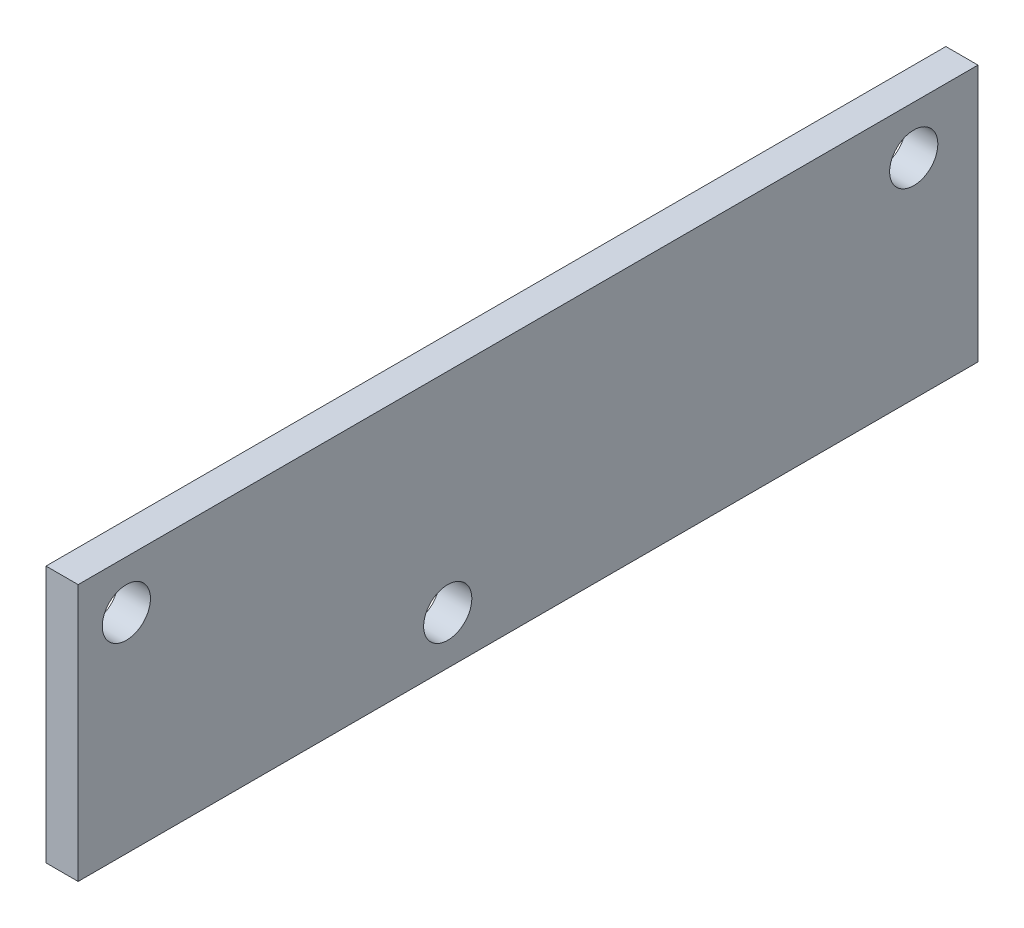
from build123d import *

# Parameters (mm, degrees)
SKETCH1_W           = 355.6
SKETCH1_H           = 101.6
BOSS_EXTRUDE1_DEPTH = 6.35
CUT_EXTRUDE1_REACH  = 14.7
SKETCH2_R           = 9.525


with BuildPart() as part:
    # Sketch1 → Boss-Extrude1 (new body, symmetric)
    with BuildSketch(Plane(origin=(0, 0, 0), x_dir=(0, 0, -1), z_dir=(1, 0, 0))):
        Rectangle(SKETCH1_W, SKETCH1_H)
    extrude(amount=BOSS_EXTRUDE1_DEPTH, both=True)

    # Sketch2 → Cut-Extrude1 (cut, up to next)
    with BuildSketch(Plane(origin=(6.35, 0, 0), x_dir=(0, 0, -1), z_dir=(1, 0, 0)), mode=Mode.PRIVATE) as cut_extrude1_sk1:
        with Locations((-158.75, 31.75)):
            Circle(SKETCH2_R)
    cut_extrude1_tool1 = extrude(cut_extrude1_sk1.sketch, amount=-CUT_EXTRUDE1_REACH, mode=Mode.PRIVATE) & part.part
    add(cut_extrude1_tool1.solids().sort_by_distance((6.35, 31.75, 158.75))[0], mode=Mode.SUBTRACT)
    # Sketch2 → Cut-Extrude1 (cut, up to next)
    with BuildSketch(Plane(origin=(6.35, 0, 0), x_dir=(0, 0, -1), z_dir=(1, 0, 0)), mode=Mode.PRIVATE) as cut_extrude1_sk2:
        with Locations((-31.75, -31.75)):
            Circle(SKETCH2_R)
    cut_extrude1_tool2 = extrude(cut_extrude1_sk2.sketch, amount=-CUT_EXTRUDE1_REACH, mode=Mode.PRIVATE) & part.part
    add(cut_extrude1_tool2.solids().sort_by_distance((6.35, -31.75, 31.75))[0], mode=Mode.SUBTRACT)
    # Sketch2 → Cut-Extrude1 (cut, up to next)
    with BuildSketch(Plane(origin=(6.35, 0, 0), x_dir=(0, 0, -1), z_dir=(1, 0, 0)), mode=Mode.PRIVATE) as cut_extrude1_sk3:
        with Locations((152.4, 31.75)):
            Circle(SKETCH2_R)
    cut_extrude1_tool3 = extrude(cut_extrude1_sk3.sketch, amount=-CUT_EXTRUDE1_REACH, mode=Mode.PRIVATE) & part.part
    add(cut_extrude1_tool3.solids().sort_by_distance((6.35, 31.75, -152.4))[0], mode=Mode.SUBTRACT)


solid = part.part
